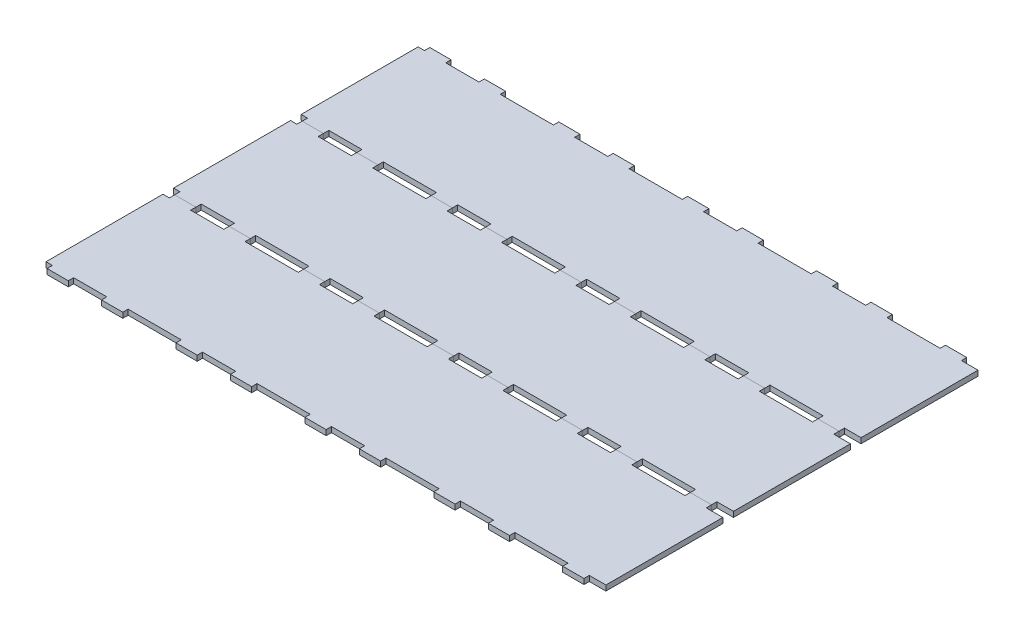
from build123d import *

# Parameters (mm, degrees)
SKETCH1_W                 = 721.63658441
SKETCH1_H                 = 152.4
BOSS_EXTRUDE1_DEPTH       = 6.35
SKETCH2_W                 = 39.679316882
SKETCH2_H                 = 6.35
SKETCH2_W_2               = 31.750000127
CUT_EXTRUDE1_DEPTH        = 7.35
LPATTERN1_COUNT           = 3
LPATTERN1_PITCH           = 153.979316882
LPATTERN1_COL_COUNT       = 3
LPATTERN1_COL_PITCH       = 153.979316882
MIRROR1_COPY_1_SKETCH_W   = 39.679316882
MIRROR1_COPY_1_SKETCH_H   = 6.35
MIRROR1_COPY_1_SKETCH_W_2 = 31.750000127
MIRROR1_COPY_1_DEPTH      = 7.35
MIRROR1_COPY_2_SKETCH_W   = 39.679316882
MIRROR1_COPY_2_SKETCH_H   = 6.35
MIRROR1_COPY_2_SKETCH_W_2 = 31.750000127
MIRROR1_COPY_2_DEPTH      = 7.35
MIRROR1_COPY_3_SKETCH_W   = 39.679316882
MIRROR1_COPY_3_SKETCH_H   = 6.35
MIRROR1_COPY_3_SKETCH_W_2 = 31.750000127
MIRROR1_COPY_3_DEPTH      = 7.35
MIRROR1_COPY_4_SKETCH_W   = 39.679316882
MIRROR1_COPY_4_SKETCH_H   = 6.35
MIRROR1_COPY_4_SKETCH_W_2 = 31.750000127
MIRROR1_COPY_4_DEPTH      = 7.35
CUT_EXTRUDE2_DEPTH        = 7.35
LPATTERN2_COUNT           = 3
LPATTERN2_PITCH           = 152.4


with BuildPart() as part:
    # Sketch1 → Boss-Extrude1 (new body)
    with BuildSketch(Plane(origin=(0, 0, 0), x_dir=(1, 0, 0), z_dir=(0, 1, 0))):
        Rectangle(SKETCH1_W, SKETCH1_H)
    extrude(amount=BOSS_EXTRUDE1_DEPTH)

    # Sketch2 → Cut-Extrude1 (cut, through all)
    with BuildSketch(Plane(origin=(0, 6.35, 0), x_dir=(1, 0, 0), z_dir=(0, 1, 0))):
        with Locations((0, -73.025)):
            Rectangle(SKETCH2_W, SKETCH2_H)
        with Locations((-61.114658505, -73.025)):
            Rectangle(SKETCH2_W_2, SKETCH2_H)
        with Locations((61.114658505, -73.025)):
            Rectangle(SKETCH2_W_2, SKETCH2_H)
    cut_extrude1 = extrude(amount=-CUT_EXTRUDE1_DEPTH, mode=Mode.SUBTRACT)

    # LPattern1: Cut-Extrude1 ×3
    with Locations(*[(i * LPATTERN1_PITCH, 0, 0) for i in range(1, LPATTERN1_COUNT)]):
        add(cut_extrude1, mode=Mode.SUBTRACT)

    # LPattern1 col: Cut-Extrude1 ×3
    with Locations(*[(-i * LPATTERN1_COL_PITCH, 0, 0) for i in range(1, LPATTERN1_COL_COUNT)]):
        add(cut_extrude1, mode=Mode.SUBTRACT)

    # Mirror1: Cut-Extrude1 across plane
    add(cut_extrude1.mirror(Plane.XY), mode=Mode.SUBTRACT)

    # Mirror1 copy 1 sketch → Mirror1 copy 1 (cut, through all)
    with BuildSketch(Plane(origin=(153.979316882, 6.35, 0), x_dir=(1, 0, 0), z_dir=(0, 1, 0))):
        with Locations((0, 73.025)):
            Rectangle(MIRROR1_COPY_1_SKETCH_W, MIRROR1_COPY_1_SKETCH_H)
        with Locations((-61.114658505, 73.025)):
            Rectangle(MIRROR1_COPY_1_SKETCH_W_2, MIRROR1_COPY_1_SKETCH_H)
        with Locations((61.114658505, 73.025)):
            Rectangle(MIRROR1_COPY_1_SKETCH_W_2, MIRROR1_COPY_1_SKETCH_H)
    extrude(amount=-MIRROR1_COPY_1_DEPTH, mode=Mode.SUBTRACT)

    # Mirror1 copy 2 sketch → Mirror1 copy 2 (cut, through all)
    with BuildSketch(Plane(origin=(307.958633764, 6.35, 0), x_dir=(1, 0, 0), z_dir=(0, 1, 0))):
        with Locations((0, 73.025)):
            Rectangle(MIRROR1_COPY_2_SKETCH_W, MIRROR1_COPY_2_SKETCH_H)
        with Locations((-61.114658505, 73.025)):
            Rectangle(MIRROR1_COPY_2_SKETCH_W_2, MIRROR1_COPY_2_SKETCH_H)
        with Locations((61.114658505, 73.025)):
            Rectangle(MIRROR1_COPY_2_SKETCH_W_2, MIRROR1_COPY_2_SKETCH_H)
    extrude(amount=-MIRROR1_COPY_2_DEPTH, mode=Mode.SUBTRACT)

    # Mirror1 copy 3 sketch → Mirror1 copy 3 (cut, through all)
    with BuildSketch(Plane(origin=(-153.979316882, 6.35, 0), x_dir=(1, 0, 0), z_dir=(0, 1, 0))):
        with Locations((0, 73.025)):
            Rectangle(MIRROR1_COPY_3_SKETCH_W, MIRROR1_COPY_3_SKETCH_H)
        with Locations((-61.114658505, 73.025)):
            Rectangle(MIRROR1_COPY_3_SKETCH_W_2, MIRROR1_COPY_3_SKETCH_H)
        with Locations((61.114658505, 73.025)):
            Rectangle(MIRROR1_COPY_3_SKETCH_W_2, MIRROR1_COPY_3_SKETCH_H)
    extrude(amount=-MIRROR1_COPY_3_DEPTH, mode=Mode.SUBTRACT)

    # Mirror1 copy 4 sketch → Mirror1 copy 4 (cut, through all)
    with BuildSketch(Plane(origin=(-307.958633764, 6.35, 0), x_dir=(1, 0, 0), z_dir=(0, 1, 0))):
        with Locations((0, 73.025)):
            Rectangle(MIRROR1_COPY_4_SKETCH_W, MIRROR1_COPY_4_SKETCH_H)
        with Locations((-61.114658505, 73.025)):
            Rectangle(MIRROR1_COPY_4_SKETCH_W_2, MIRROR1_COPY_4_SKETCH_H)
        with Locations((61.114658505, 73.025)):
            Rectangle(MIRROR1_COPY_4_SKETCH_W_2, MIRROR1_COPY_4_SKETCH_H)
    extrude(amount=-MIRROR1_COPY_4_DEPTH, mode=Mode.SUBTRACT)

    # Sketch3 → Cut-Extrude2 (cut, through all)
    with BuildSketch(Plane(origin=(0, 6.35, 0), x_dir=(1, 0, 0), z_dir=(0, 1, 0))):
        Polygon((307.958633764, 69.85), (307.958633764, -76.2), (360.818292205, -76.2), (360.818292205, 76.2), (307.958633764, 76.2), align=None)
    extrude(amount=-CUT_EXTRUDE2_DEPTH, mode=Mode.SUBTRACT)


with BuildPart() as lpattern2_1:
    # LPattern2: pattern copy
    add(part.part.moved(Location(Vector(0, 0, 1) * (1 * LPATTERN2_PITCH))))


with BuildPart() as lpattern2_2:
    # LPattern2: pattern copy
    add(part.part.moved(Location(Vector(0, 0, 1) * (2 * LPATTERN2_PITCH))))


solid = Compound([part.part, lpattern2_1.part, lpattern2_2.part])
